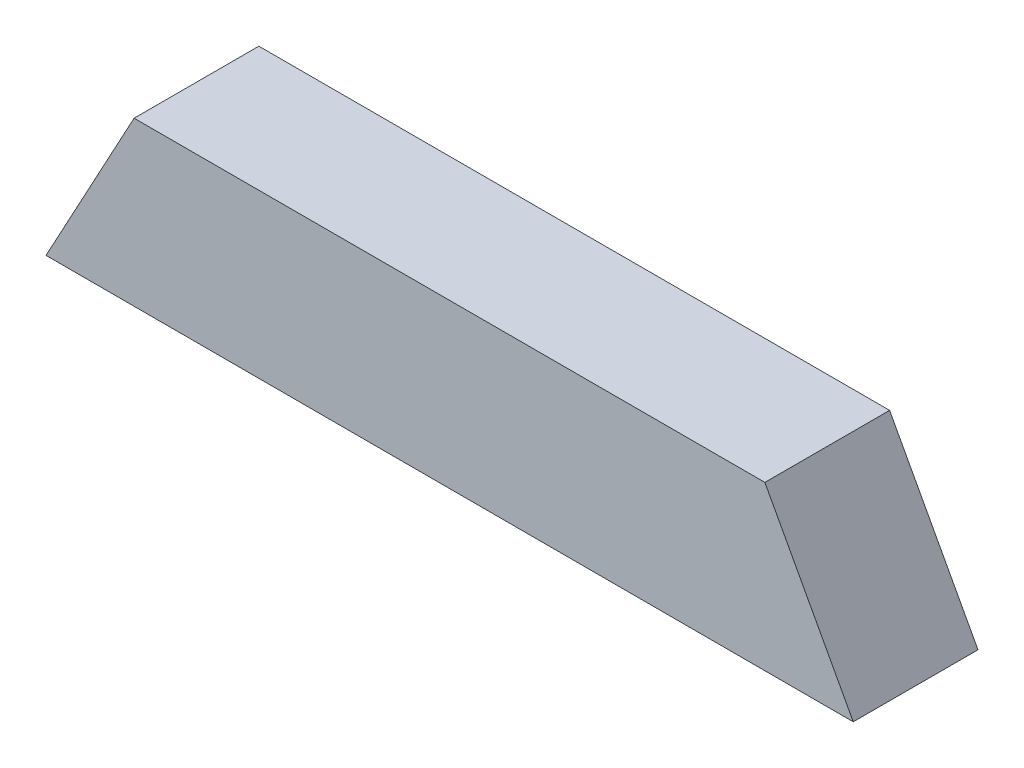
from build123d import *

# Parameters (mm, degrees)
BOSS_EXTRUDE3_DEPTH = 38
BOSS_EXTRUDE4_DEPTH = 6


with BuildPart() as part:
    # Sketch1 → Boss-Extrude3 (new body)
    with BuildSketch(Plane.XY):
        Polygon((-107.68463, 30.25), (107.648903001, 30.25), (132.321905897, -15.300159192), (135.572573725, -21.301392104), (142.39764743, -21.30397981), (111.222575033, 36.25), (-111.260793608, 36.25), (-142.331864382, -21.196025493), (-135.511854399, -21.198611279), (-132.267274575, -15.19984102), align=None)
    extrude(amount=BOSS_EXTRUDE3_DEPTH)

    # Sketch1_3 → Boss-Extrude4 (add)
    with BuildSketch(Plane.XY):
        Polygon((142.39764743, -21.30397981), (111.222575033, 36.25), (-111.260793608, 36.25), (-142.331864382, -21.196025493), align=None)
    boss_extrude4 = extrude(amount=-BOSS_EXTRUDE4_DEPTH)

    # Mirror1: Boss-Extrude4 across plane
    add(boss_extrude4.mirror(Plane(origin=(0, 0, 16), x_dir=(1, 0, 0), z_dir=(0, 0, -1))))


solid = part.part
